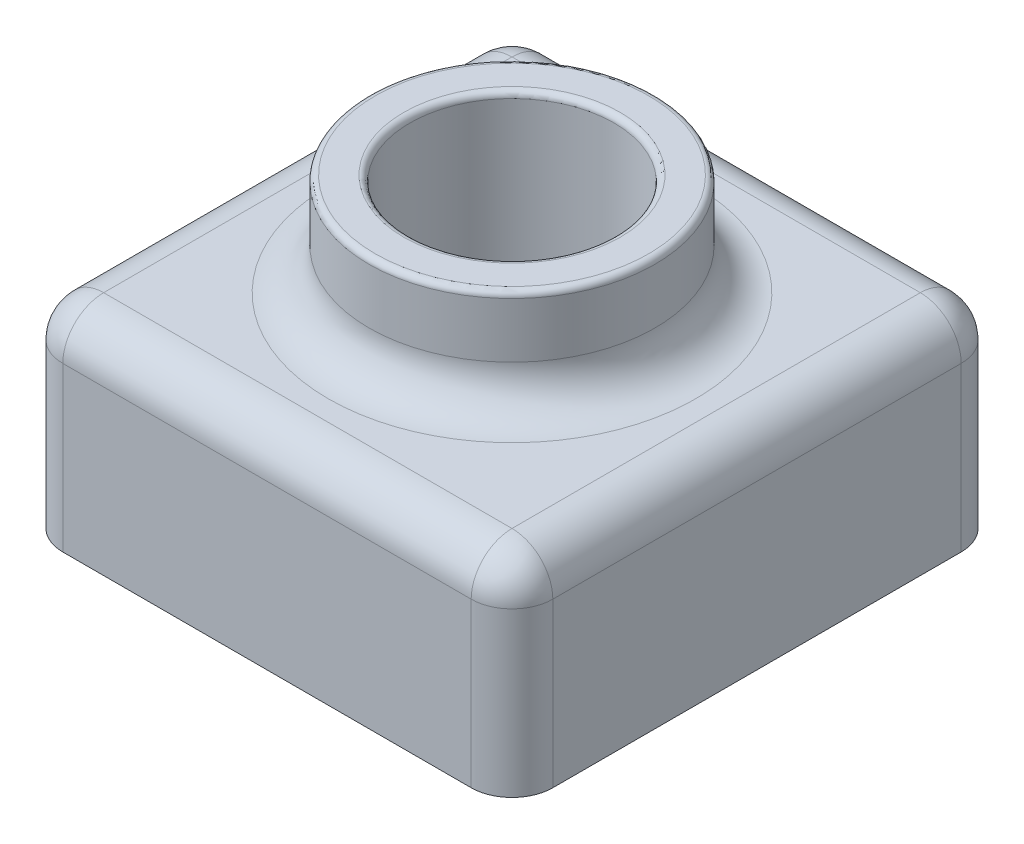
from build123d import *

# Parameters (mm, degrees)
SKETCH3_W           = 120
SKETCH3_H           = 120
BOSS_EXTRUDE2_DEPTH = 50
SKETCH4_R           = 35
BOSS_EXTRUDE3_DEPTH = 25
SKETCH9_R           = 25
CUT_EXTRUDE3_DEPTH  = 186.539753153
FILLET4_R           = 10
FILLET5_R           = 1.5
SHELL2_T            = -2


with BuildPart() as part:
    # Sketch3 → Boss-Extrude2 (new body)
    with BuildSketch(Plane(origin=(0, 0, 0), x_dir=(1, 0, 0), z_dir=(0, 1, 0))):
        with Locations((60, 60)):
            Rectangle(SKETCH3_W, SKETCH3_H)
    extrude(amount=BOSS_EXTRUDE2_DEPTH)

    # Sketch4 → Boss-Extrude3 (add)
    with BuildSketch(Plane(origin=(0, 50, 0), x_dir=(1, 0, 0), z_dir=(0, 1, 0))):
        with Locations(Location((60, 60, 0), (0, 0, 270))):
            Circle(SKETCH4_R)
    extrude(amount=BOSS_EXTRUDE3_DEPTH)

    # Sketch9 → Cut-Extrude3 (cut, through all)
    with BuildSketch(Plane(origin=(0, 75, 0), x_dir=(1, 0, 0), z_dir=(0, 1, 0))):
        with Locations(Location((60, 60, 0), (0, 0, 270))):
            Circle(SKETCH9_R)
    extrude(amount=-CUT_EXTRUDE3_DEPTH, mode=Mode.SUBTRACT)

    # Fillet4
    fillet4_edges = [part.edges().sort_by_distance(p)[0] for p in [
        (60, 50, 0),
        (60, 50, -95),
        (0, 50, -60),
        (60, 50, -120),
        (0, 25, -120),
        (0, 25, 0),
        (120, 25, 0),
        (120, 25, -120),
        (120, 50, -60),
    ]]
    fillet(fillet4_edges, radius=FILLET4_R)

    # Fillet5
    fillet5_edges = [part.edges().sort_by_distance(p)[0] for p in [
        (60, 75, -95),
        (60, 75, -85),
    ]]
    fillet(fillet5_edges, radius=FILLET5_R)

    # Shell2
    shell2_openings = [part.faces().sort_by_distance(p)[0] for p in [
        (60, 0, -1.697056275),
    ]]
    offset(amount=SHELL2_T, openings=shell2_openings, kind=Kind.INTERSECTION)


solid = part.part
